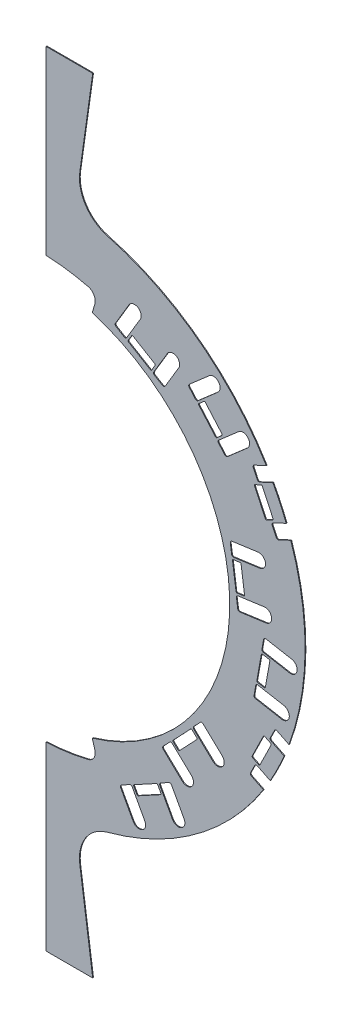
from build123d import *

# Parameters (mm, degrees)
EXTRUDE1_DEPTH                      = 0.205
EXTRUDE2_DEPTH                      = 0.41
FILLET3_R                           = 5
MOUSE_HOLE_CUT_EXTRUDE4_DEPTH       = 1.41
MOUSE_HOLE_CUT_EXTRUDE1_DEPTH       = 1.41
FILLET4_R                           = 1
MOUSE_HOLE_CUT_EXTRUDE3_DEPTH       = 1.41
FILLET2_R                           = 1
LADDER_MOUNT_HOLE_EXTRUDE7_DEPTH    = 1.41
LADDER_MOUNT_HOLE_EXTRUDE8_DEPTH    = 1.41
LADDER_MOUNT_HOLE_EXTRUDE11_DEPTH   = 1.41
LADDER_MOUNT_HOLE_CIRPATTERN1_COUNT = 3
LADDER_MOUNT_HOLE_CIRPATTERN1_ANGLE = 102.52629862
LADDER_MOUNT_HOLE_CIRPATTERN2_COUNT = 2
LADDER_MOUNT_HOLE_CIRPATTERN2_ANGLE = 51.26314931
MOUSE_HOLE_CIRPATTERN3_COUNT        = 3
MOUSE_HOLE_CIRPATTERN3_ANGLE        = 102.52629862
FILLET4_OF_MOUSE_HOLE_CIRPATTERN3_R = 1
MOUSE_HOLE_CIRPATTERN4_COUNT        = 2
MOUSE_HOLE_CIRPATTERN4_ANGLE        = 51.26314931
FILLET2_OF_MOUSE_HOLE_CIRPATTERN4_R = 1


with BuildPart() as part:
    # Sketch1 → Extrude1 (new body, symmetric)
    with BuildSketch(Plane.XY):
        with BuildLine():
            Line((22.373563978, 159.196179712), (29.232493618, 208))
            Line((29.232493618, 208), (4.5, 208))
            Line((4.5, 208), (4.5, 111.909561701))
            ThreePointArc((4.5, 111.909561701), (112, 0), (4.5, -111.909561701))
            Line((4.5, -111.909561701), (4.5, -208))
            Line((4.5, -208), (29.232493618, -208))
            Line((29.232493618, -208), (22.373563978, -159.196179712))
            ThreePointArc((22.373563978, -159.196179712), (25.492385871, -145.387319735), (36.971650618, -137.102505632))
            ThreePointArc((36.971650618, -137.102505632), (142, 0), (36.971650618, 137.102505632))
            ThreePointArc((36.971650618, 137.102505632), (25.492385871, 145.387319735), (22.373563978, 159.196179712))
        make_face()
    extrude(amount=EXTRUDE1_DEPTH, both=True)

    # Sketch2 → Extrude2 (add)
    with BuildSketch(Plane.XY.offset(0.205)):
        with BuildLine():
            Line((31.809718607, 107.387810305), (28.96956516, 97.799612957))
            ThreePointArc((28.96956516, 97.799612957), (102, 0), (28.96956516, -97.799612957))
            Line((28.96956516, -97.799612957), (31.809718607, -107.387810305))
            ThreePointArc((31.809718607, -107.387810305), (112, 0), (31.809718607, 107.387810305))
        make_face()
    extrude(amount=-EXTRUDE2_DEPTH)

    # Fillet3
    fillet3_edges = [part.edges().sort_by_distance(p)[0] for p in [
        (31.809718607, -107.387810305, 0),
        (31.809718607, 107.387810305, 0),
    ]]
    fillet(fillet3_edges, radius=FILLET3_R)

    # Sketch5 → Mouse Hole Cut-Extrude4 (cut, through all)
    with BuildSketch(Plane.XY.offset(0.205)):
        with BuildLine():
            Line((67.174381022, 82.47589017), (61.164862299, 86.065553765))
            Line((61.164862299, 86.065553765), (68.856998574, 98.943093884))
            ThreePointArc((68.856998574, 98.943093884), (73.656589733, 100.153021448), (74.866517297, 95.353430289))
            Line((74.866517297, 95.353430289), (67.174381022, 82.47589017))
        make_face()
        with BuildLine():
            Line((48.467560052, 111.122309653), (40.775423777, 98.244769534))
            Line((40.775423777, 98.244769534), (46.784942499, 94.655105938))
            Line((46.784942499, 94.655105938), (54.477078774, 107.532646058))
            ThreePointArc((54.477078774, 107.532646058), (53.267151211, 112.332237217), (48.467560052, 111.122309653))
        make_face()
    mouse_hole_cut_extrude4 = extrude(amount=-MOUSE_HOLE_CUT_EXTRUDE4_DEPTH, mode=Mode.SUBTRACT)

    # Sketch3 → Mouse Hole Cut-Extrude1 (cut, through all)
    with BuildSketch(Plane.XY.offset(0.205)):
        with BuildLine():
            Line((79.789058848, 90.023565589), (84.391221028, 84.749089001))
            Line((84.391221028, 84.749089001), (95.693670858, 94.610865101))
            ThreePointArc((95.693670858, 94.610865101), (96.029828062, 99.549184485), (91.091508678, 99.885341688))
            Line((91.091508678, 99.885341688), (79.789058848, 90.023565589))
        make_face()
        with BuildLine():
            Line((111.308149683, 76.715319537), (100.005699853, 66.853543437))
            Line((100.005699853, 66.853543437), (95.403537673, 72.128020025))
            Line((95.403537673, 72.128020025), (106.705987503, 81.989796124))
            ThreePointArc((106.705987503, 81.989796124), (111.644306887, 81.653638921), (111.308149683, 76.715319537))
        make_face()
    mouse_hole_cut_extrude1 = extrude(amount=-MOUSE_HOLE_CUT_EXTRUDE1_DEPTH, mode=Mode.SUBTRACT)

    # Fillet4
    fillet4_edges = [part.edges().sort_by_distance(p)[0] for p in [
        (79.789058848, 90.023565589, 0),
        (84.391221028, 84.749089001, 0),
        (67.174381022, 82.47589017, 0),
        (61.164862299, 86.065553765, 0),
        (46.784942499, 94.655105938, 0),
        (40.775423777, 98.244769534, 0),
        (100.005699853, 66.853543437, 0),
        (95.403537673, 72.128020025, 0),
    ]]
    fillet(fillet4_edges, radius=FILLET4_R)

    # Sketch4 → Mouse Hole Cut-Extrude3 (cut, through all)
    with BuildSketch(Plane.XY.offset(0.205)):
        with BuildLine():
            Line((124.125444221, 48.765892697), (127.089215564, 42.424279383))
            Line((127.089215564, 42.424279383), (134.39757133, 45.839860608))
            ThreePointArc((134.39757133, 45.839860608), (133.22262306, 49.150103815), (131.966156779, 52.43027241))
            Line((131.966156779, 52.43027241), (124.125444221, 48.765892697))
        make_face()
        with BuildLine():
            Line((114.069791453, 70.282080729), (121.37814722, 73.697661954))
            ThreePointArc((121.37814722, 73.697661954), (123.163892858, 70.672876666), (124.874275353, 67.604847127))
            Line((124.874275353, 67.604847127), (117.033562795, 63.940467414))
            Line((117.033562795, 63.940467414), (114.069791453, 70.282080729))
        make_face()
    mouse_hole_cut_extrude3 = extrude(amount=-MOUSE_HOLE_CUT_EXTRUDE3_DEPTH, mode=Mode.SUBTRACT)

    # Fillet2
    fillet2_edges = [part.edges().sort_by_distance(p)[0] for p in [
        (117.033562795, 63.940467414, 0),
        (114.069791453, 70.282080729, 0),
        (127.089215564, 42.424279383, 0),
        (124.125444221, 48.765892697, 0),
    ]]
    fillet(fillet2_edges, radius=FILLET2_R)

    # Sketch6 → Ladder Mount Hole Extrude7 (cut, through all)
    with BuildSketch(Plane.XY.offset(0.205)):
        with BuildLine():
            Line((59.837999061, 87.013049383), (48.248212954, 93.935972031))
            ThreePointArc((48.248212954, 93.935972031), (48.019785574, 94.243002228), (48.075366159, 94.621627911))
            Line((48.075366159, 94.621627911), (49.91327392, 97.698501497))
            ThreePointArc((49.91327392, 97.698501497), (50.220304116, 97.926928876), (50.598929799, 97.871348292))
            Line((50.598929799, 97.871348292), (62.188715907, 90.948425644))
            ThreePointArc((62.188715907, 90.948425644), (62.417143287, 90.641395447), (62.361562702, 90.262769764))
            Line((62.361562702, 90.262769764), (60.523654941, 87.185896178))
            ThreePointArc((60.523654941, 87.185896178), (60.216624744, 86.957468799), (59.837999061, 87.013049383))
        make_face()
    ladder_mount_hole_extrude7 = extrude(amount=-LADDER_MOUNT_HOLE_EXTRUDE7_DEPTH, mode=Mode.SUBTRACT)

    # Sketch7 → Ladder Mount Hole Extrude8 (cut, through all)
    with BuildSketch(Plane.XY.offset(0.205)):
        with BuildLine():
            Line((85.559795161, 83.612098018), (94.435393651, 73.439893171))
            ThreePointArc((94.435393651, 73.439893171), (94.778184973, 73.269773452), (95.140867848, 73.391870713))
            Line((95.140867848, 73.391870713), (97.841399861, 75.748177749))
            ThreePointArc((97.841399861, 75.748177749), (98.01151958, 76.090969072), (97.889422319, 76.453651947))
            Line((97.889422319, 76.453651947), (89.013823829, 86.625856794))
            ThreePointArc((89.013823829, 86.625856794), (88.671032507, 86.795976513), (88.308349631, 86.673879252))
            Line((88.308349631, 86.673879252), (85.607817619, 84.317572216))
            ThreePointArc((85.607817619, 84.317572216), (85.437697899, 83.974780893), (85.559795161, 83.612098018))
        make_face()
    ladder_mount_hole_extrude8 = extrude(amount=-LADDER_MOUNT_HOLE_EXTRUDE8_DEPTH, mode=Mode.SUBTRACT)

    # Sketch8 → Ladder Mount Hole Extrude11 (cut, through all)
    with BuildSketch(Plane.XY.offset(0.205)):
        with BuildLine():
            Line((119.309273033, 63.210319582), (125.025117764, 50.980065332))
            ThreePointArc((125.025117764, 50.980065332), (125.042138284, 50.597760596), (124.783843338, 50.315395))
            Line((124.783843338, 50.315395), (121.536937321, 48.797944072))
            ThreePointArc((121.536937321, 48.797944072), (121.154632584, 48.780923552), (120.872266988, 49.039218499))
            Line((120.872266988, 49.039218499), (115.156422257, 61.269472748))
            ThreePointArc((115.156422257, 61.269472748), (115.139401737, 61.651777485), (115.397696683, 61.934143081))
            Line((115.397696683, 61.934143081), (118.6446027, 63.451594008))
            ThreePointArc((118.6446027, 63.451594008), (119.026907436, 63.468614528), (119.309273033, 63.210319582))
        make_face()
    ladder_mount_hole_extrude11 = extrude(amount=-LADDER_MOUNT_HOLE_EXTRUDE11_DEPTH, mode=Mode.SUBTRACT)

    # Ladder Mount Hole CirPattern1: Ladder Mount Hole Extrude7, Ladder Mount Hole Extrude8 ×3 about axis
    ladder_mount_hole_cirpattern1_axis = Axis((0, 0, 0), (0, 0, -1))
    add([ladder_mount_hole_extrude7.rotate(ladder_mount_hole_cirpattern1_axis, i * LADDER_MOUNT_HOLE_CIRPATTERN1_ANGLE / (LADDER_MOUNT_HOLE_CIRPATTERN1_COUNT - 1)) for i in range(1, LADDER_MOUNT_HOLE_CIRPATTERN1_COUNT)], mode=Mode.SUBTRACT)
    add([ladder_mount_hole_extrude8.rotate(ladder_mount_hole_cirpattern1_axis, i * LADDER_MOUNT_HOLE_CIRPATTERN1_ANGLE / (LADDER_MOUNT_HOLE_CIRPATTERN1_COUNT - 1)) for i in range(1, LADDER_MOUNT_HOLE_CIRPATTERN1_COUNT)], mode=Mode.SUBTRACT)

    # Ladder Mount Hole CirPattern2: Ladder Mount Hole Extrude11 ×2 about axis
    ladder_mount_hole_cirpattern2_axis = Axis((0, 0, 0), (0, 0, -1))
    for i in range(1, LADDER_MOUNT_HOLE_CIRPATTERN2_COUNT):
        add(ladder_mount_hole_extrude11.rotate(ladder_mount_hole_cirpattern2_axis, i * LADDER_MOUNT_HOLE_CIRPATTERN2_ANGLE / (LADDER_MOUNT_HOLE_CIRPATTERN2_COUNT - 1)), mode=Mode.SUBTRACT)

    # Mouse Hole CirPattern3: Mouse Hole Cut-Extrude4, Mouse Hole Cut-Extrude1 ×3 about axis
    mouse_hole_cirpattern3_axis = Axis((0, 0, 0), (0, 0, -1))
    add([mouse_hole_cut_extrude4.rotate(mouse_hole_cirpattern3_axis, i * MOUSE_HOLE_CIRPATTERN3_ANGLE / (MOUSE_HOLE_CIRPATTERN3_COUNT - 1)) for i in range(1, MOUSE_HOLE_CIRPATTERN3_COUNT)], mode=Mode.SUBTRACT)
    add([mouse_hole_cut_extrude1.rotate(mouse_hole_cirpattern3_axis, i * MOUSE_HOLE_CIRPATTERN3_ANGLE / (MOUSE_HOLE_CIRPATTERN3_COUNT - 1)) for i in range(1, MOUSE_HOLE_CIRPATTERN3_COUNT)], mode=Mode.SUBTRACT)

    # Fillet4 of Mouse Hole CirPattern3
    fillet4_of_mouse_hole_cirpattern3_edges = [part.edges().sort_by_distance(p)[0] for p in [
        (120.148474426, -5.905960245, 0),
        (118.914011964, -12.796250691, 0),
        (106.367510493, -0.789073105, 0),
        (105.40712588, 6.144732588, 0),
        (103.109062699, 22.736339069, 0),
        (102.148678086, 29.670144762, 0),
        (114.725657185, -36.174021848, 0),
        (115.960119646, -29.283731402, 0),
        (70.575428818, -97.414809553, 0),
        (64.428350514, -100.763455297, 0),
        (65.943382614, -83.463406439, 0),
        (70.750990608, -78.375488852, 0),
        (82.254909739, -66.200828913, 0),
        (87.062517734, -61.112911326, 0),
        (43.572191979, -112.124931926, 0),
        (49.719270284, -108.776286182, 0),
    ]]
    fillet(fillet4_of_mouse_hole_cirpattern3_edges, radius=FILLET4_OF_MOUSE_HOLE_CIRPATTERN3_R)

    # Mouse Hole CirPattern4: Mouse Hole Cut-Extrude3 ×2 about axis
    mouse_hole_cirpattern4_axis = Axis((0, 0, 0), (0, 0, -1))
    for i in range(1, MOUSE_HOLE_CIRPATTERN4_COUNT):
        add(mouse_hole_cut_extrude3.rotate(mouse_hole_cirpattern4_axis, i * MOUSE_HOLE_CIRPATTERN4_ANGLE / (MOUSE_HOLE_CIRPATTERN4_COUNT - 1)), mode=Mode.SUBTRACT)

    # Fillet2 of Mouse Hole CirPattern4
    fillet2_of_mouse_hole_cirpattern4_edges = [part.edges().sort_by_distance(p)[0] for p in [
        (123.108467123, -51.279074838, 0),
        (126.200540242, -44.999020394, 0),
        (112.617504757, -72.586402419, 0),
        (115.709577875, -66.306347974, 0),
    ]]
    fillet(fillet2_of_mouse_hole_cirpattern4_edges, radius=FILLET2_OF_MOUSE_HOLE_CIRPATTERN4_R)


solid = part.part
